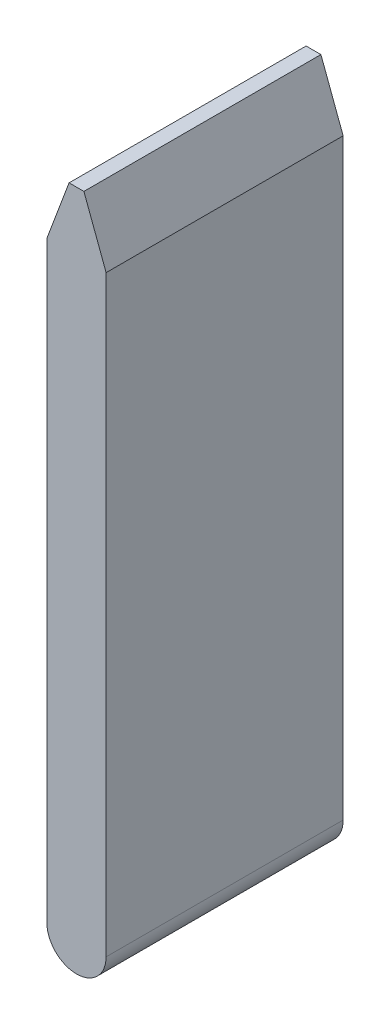
from build123d import *

# Parameters (mm, degrees)
SALIENTE_EXTRUIR5_DEPTH = 80


with BuildPart() as part:
    # Croquis6 → Saliente-Extruir5 (new body)
    with BuildSketch(Plane.XY):
        with BuildLine():
            Line((-10, 200), (-10, 0))
            ThreePointArc((-10, 0), (0, -10), (10, 0))
            Line((10, 0), (10, 200))
            Line((10, 200), (2.5, 220))
            Line((2.5, 220), (-2.5, 220))
            Line((-2.5, 220), (-10, 200))
        make_face()
    extrude(amount=SALIENTE_EXTRUIR5_DEPTH)


solid = part.part
